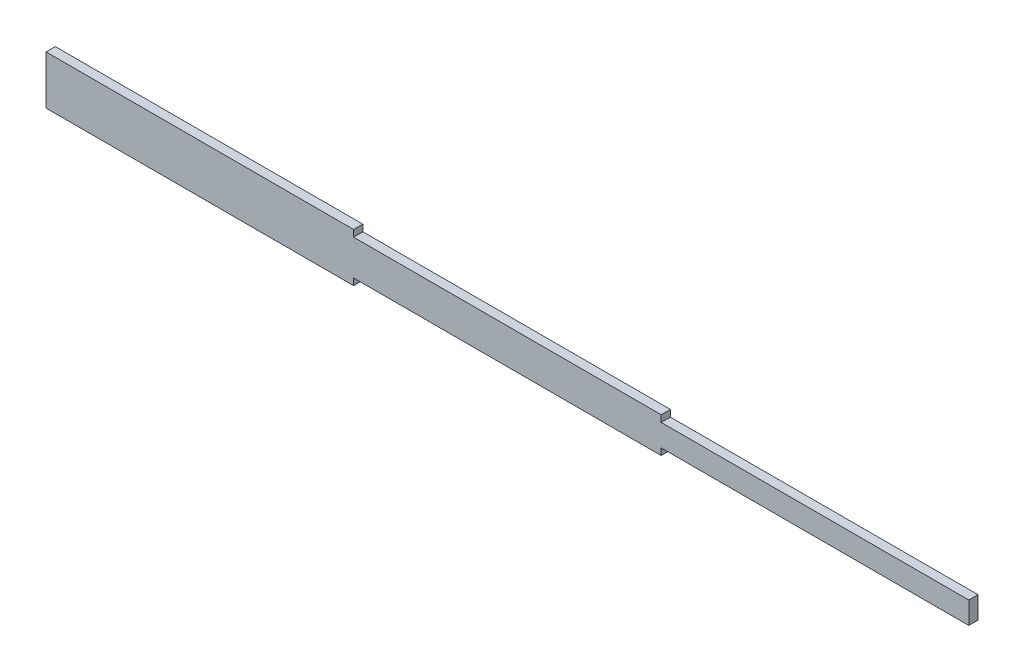
from build123d import *

# Parameters (mm, degrees)
SKETCH1_W           = 30
SKETCH1_H           = 158.25
BOSS_EXTRUDE1_DEPTH = 1000
SKETCH3_W           = 30
SKETCH3_H           = 114.95
BOSS_EXTRUDE2_DEPTH = 1000
SKETCH4_W           = 30
SKETCH4_H           = 71.65
BOSS_EXTRUDE3_DEPTH = 1000
SKETCH5_W           = 26
SKETCH5_H           = 154.25
CUT_EXTRUDE1_DEPTH  = 998
SKETCH6_W           = 26
SKETCH6_H           = 110.95
CUT_EXTRUDE2_DEPTH  = 998
SKETCH7_W           = 26
SKETCH7_H           = 67.65
CUT_EXTRUDE3_DEPTH  = 998


with BuildPart() as part:
    # Sketch1 → Boss-Extrude1 (new body)
    with BuildSketch(Plane(origin=(0, 0, 0), x_dir=(0, 0, -1), z_dir=(1, 0, 0))):
        Rectangle(SKETCH1_W, SKETCH1_H)
    extrude(amount=BOSS_EXTRUDE1_DEPTH)

    # Sketch3 → Boss-Extrude2 (add)
    with BuildSketch(Plane(origin=(1000, 0, 0), x_dir=(0, 0, -1), z_dir=(1, 0, 0))):
        Rectangle(SKETCH3_W, SKETCH3_H)
    extrude(amount=BOSS_EXTRUDE2_DEPTH)

    # Sketch4 → Boss-Extrude3 (add)
    with BuildSketch(Plane(origin=(2000, 0, 0), x_dir=(0, 0, -1), z_dir=(1, 0, 0))):
        Rectangle(SKETCH4_W, SKETCH4_H)
    extrude(amount=BOSS_EXTRUDE3_DEPTH)

    # Sketch5 → Cut-Extrude1 (cut)
    with BuildSketch(Plane.ZY):
        Rectangle(SKETCH5_W, SKETCH5_H)
    extrude(amount=-CUT_EXTRUDE1_DEPTH, mode=Mode.SUBTRACT)

    # Sketch6 → Cut-Extrude2 (cut)
    with BuildSketch(Plane.ZY.offset(-998)):
        Rectangle(SKETCH6_W, SKETCH6_H)
    extrude(amount=-CUT_EXTRUDE2_DEPTH, mode=Mode.SUBTRACT)

    # Sketch7 → Cut-Extrude3 (cut)
    with BuildSketch(Plane.ZY.offset(-1996)):
        Rectangle(SKETCH7_W, SKETCH7_H)
    extrude(amount=-CUT_EXTRUDE3_DEPTH, mode=Mode.SUBTRACT)


solid = part.part
